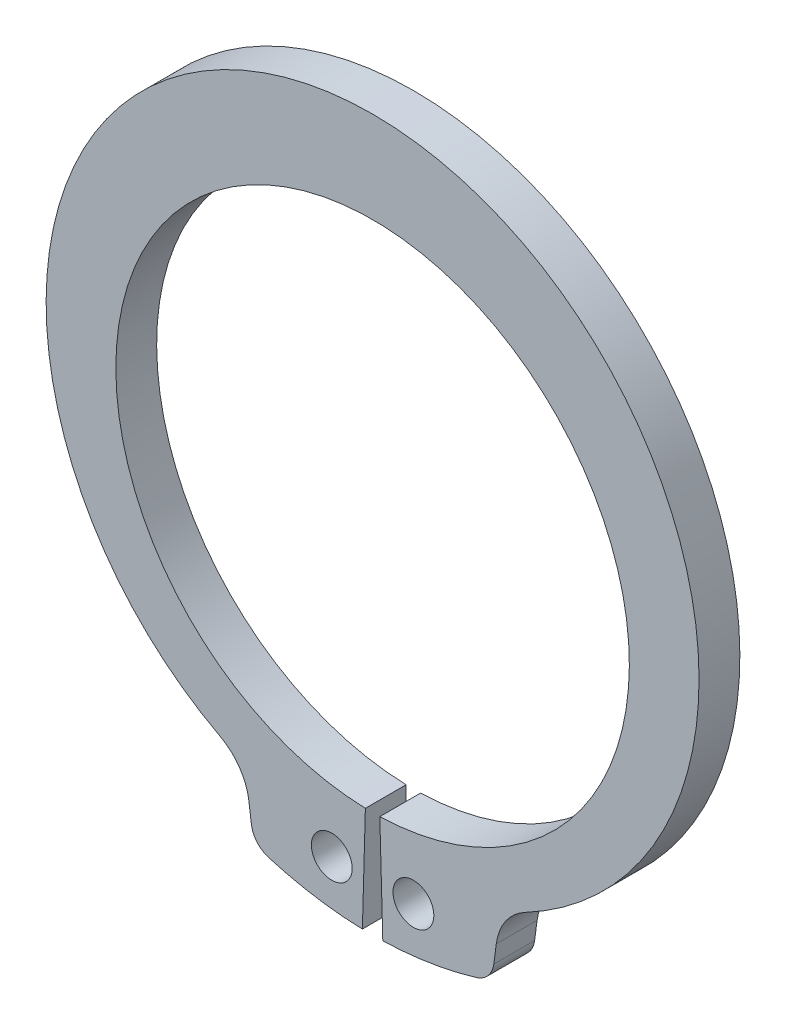
from build123d import *

# Parameters (mm, degrees)
BODYSKE_R  = 0.635
BODY_DEPTH = 1.27


with BuildPart() as part:
    # BodySke → Body (new body)
    with BuildSketch(Plane.XY):
        with BuildLine():
            Line((0.224642857, -7.98514073), (0.3175, -11.285834831))
            ThreePointArc((0.3175, -11.285834831), (1.791109605, -11.14732257), (3.23393725, -10.817232731))
            ThreePointArc((3.23393725, -10.817232731), (3.595727324, -10.581308403), (3.771154753, -10.186621739))
            Line((3.771154753, -10.186621739), (3.848242386, -9.601083037))
            ThreePointArc((3.848242386, -9.601083037), (4.142275713, -8.841092018), (4.752146865, -8.300630063))
            ThreePointArc((4.752146865, -8.300630063), (0, 10.8331), (-4.752146865, -8.300630063))
            ThreePointArc((-4.752146865, -8.300630063), (-4.142275713, -8.841092018), (-3.848242386, -9.601083037))
            Line((-3.848242386, -9.601083037), (-3.771154753, -10.186621739))
            ThreePointArc((-3.771154753, -10.186621739), (-3.595727324, -10.581308403), (-3.23393725, -10.817232731))
            ThreePointArc((-3.23393725, -10.817232731), (-1.791109605, -11.14732257), (-0.3175, -11.285834831))
            Line((-0.3175, -11.285834831), (-0.224642857, -7.98514073))
            ThreePointArc((-0.224642857, -7.98514073), (0, 7.9883), (0.224642857, -7.98514073))
        make_face()
        with Locations((1.27, -9.811446626)):
            Circle(BODYSKE_R, mode=Mode.SUBTRACT)
        with Locations((-1.27, -9.811446626)):
            Circle(BODYSKE_R, mode=Mode.SUBTRACT)
    extrude(amount=-BODY_DEPTH)


solid = part.part
